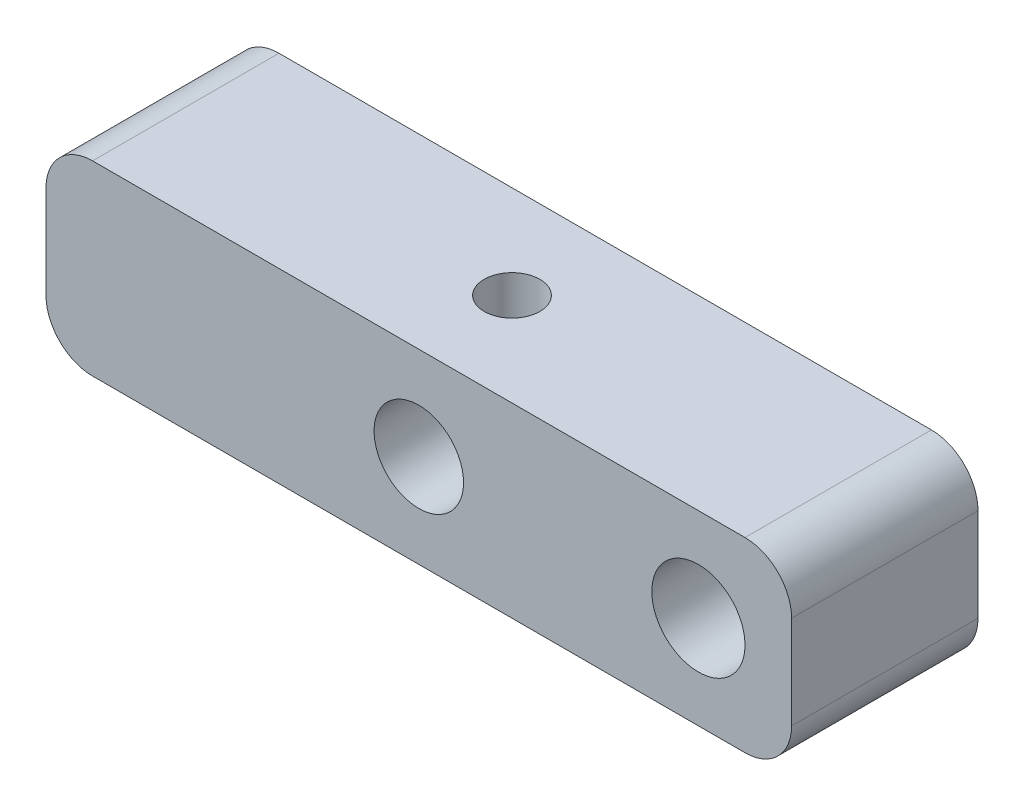
from build123d import *

# Parameters (mm, degrees)
SKETCH1_W                       = 50.8
SKETCH1_H                       = 12.7
BOSS_EXTRUDE1_DEPTH             = 12.7
SKETCH4_R                       = 3.048
CUT_EXTRUDE1_DEPTH              = 50.8
SKETCH6_R                       = 3.175
CUT_EXTRUDE2_DEPTH              = 50.8
TAP_DRILL_FOR_10_24_TAP1_REACH  = 31.099
TAP_DRILL_FOR_10_24_TAP1_BORE_R = 1.89865
FILLET1_R                       = 3.175


with BuildPart() as part:
    # Sketch1 → Boss-Extrude1 (new body)
    with BuildSketch(Plane.XY):
        Rectangle(SKETCH1_W, SKETCH1_H)
    extrude(amount=BOSS_EXTRUDE1_DEPTH)

    # Sketch4 → Cut-Extrude1 (cut)
    with BuildSketch(Plane.XY.offset(12.7)):
        Circle(SKETCH4_R)
    extrude(amount=-CUT_EXTRUDE1_DEPTH, mode=Mode.SUBTRACT)

    # Sketch6 → Cut-Extrude2 (cut)
    with BuildSketch(Plane.XY.offset(12.7)):
        with Locations((19.05, 0)):
            Circle(SKETCH6_R)
    extrude(amount=-CUT_EXTRUDE2_DEPTH, mode=Mode.SUBTRACT)

    # Tap Drill for #10-24 Tap1 bore (on position points) → Tap Drill for #10-24 Tap1 (cut, up to next)
    with BuildSketch(Plane(origin=(0, 6.35, 6.35), x_dir=(1, 0, 0), z_dir=(0, 1, 0)), mode=Mode.PRIVATE) as tap_drill_for_10_24_tap1_sk1:
        Circle(TAP_DRILL_FOR_10_24_TAP1_BORE_R)
    tap_drill_for_10_24_tap1_tool1 = extrude(tap_drill_for_10_24_tap1_sk1.sketch, amount=-TAP_DRILL_FOR_10_24_TAP1_REACH, mode=Mode.PRIVATE) & part.part
    add(tap_drill_for_10_24_tap1_tool1.solids().sort_by_distance((0, 6.35, 6.35))[0], mode=Mode.SUBTRACT)

    # Fillet1
    fillet1_edges = [part.edges().sort_by_distance(p)[0] for p in [
        (-25.4, 6.35, 6.35),
        (25.4, 6.35, 6.35),
        (25.4, -6.35, 6.35),
        (-25.4, -6.35, 6.35),
    ]]
    fillet(fillet1_edges, radius=FILLET1_R)


solid = part.part
